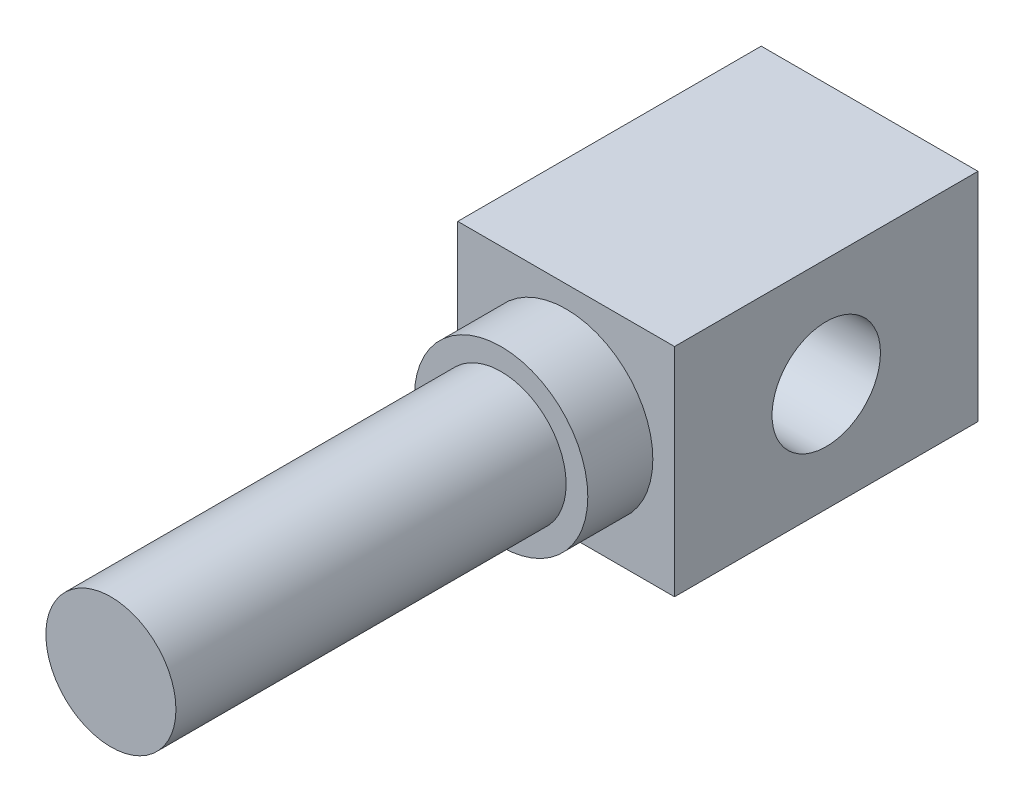
from build123d import *

# Parameters (mm, degrees)
SKETCH_1_W             = 5
SKETCH_1_H             = 5
EXTRUDE_1_DEPTH        = 7
SKETCH_2_R             = 2
EXTRUDE_2_DEPTH        = 1.5
SKETCH_3_R             = 1.5
EXTRUDE_3_DEPTH        = 9
HOLE_WIZARD_M3_2_D     = 2.5
HOLE_WIZARD_M3_2_DEPTH = 7.5
HOLE_WIZARD_M3_2_TIP   = 0.751075774


with BuildPart() as part:
    # 草图1 → 凸台-拉伸1 (new body)
    with BuildSketch(Plane.XY):
        with Locations((2.5, 2.5)):
            Rectangle(SKETCH_1_W, SKETCH_1_H)
    extrude(amount=EXTRUDE_1_DEPTH)

    # 草图2 → 凸台-拉伸2 (add)
    with BuildSketch(Plane.XY.offset(7)):
        with Locations((2.5, 2.5)):
            Circle(SKETCH_2_R)
    extrude(amount=EXTRUDE_2_DEPTH)

    # 草图3 → 凸台-拉伸3 (add)
    with BuildSketch(Plane.XY.offset(8.5)):
        with Locations((2.5, 2.5)):
            Circle(SKETCH_3_R)
    extrude(amount=EXTRUDE_3_DEPTH)

    # M3 螺纹孔2
    with Locations(Plane(origin=(5, 2.5, 3.5), x_dir=(0, 0, 1), z_dir=(1, 0, 0))):
        with Locations((0, 0)):
            Hole(HOLE_WIZARD_M3_2_D / 2, depth=HOLE_WIZARD_M3_2_DEPTH)
            with Locations((0, 0, -(HOLE_WIZARD_M3_2_DEPTH + HOLE_WIZARD_M3_2_TIP / 2))):  # 118° drill point
                Cone(0, HOLE_WIZARD_M3_2_D / 2, HOLE_WIZARD_M3_2_TIP, mode=Mode.SUBTRACT)


solid = part.part
